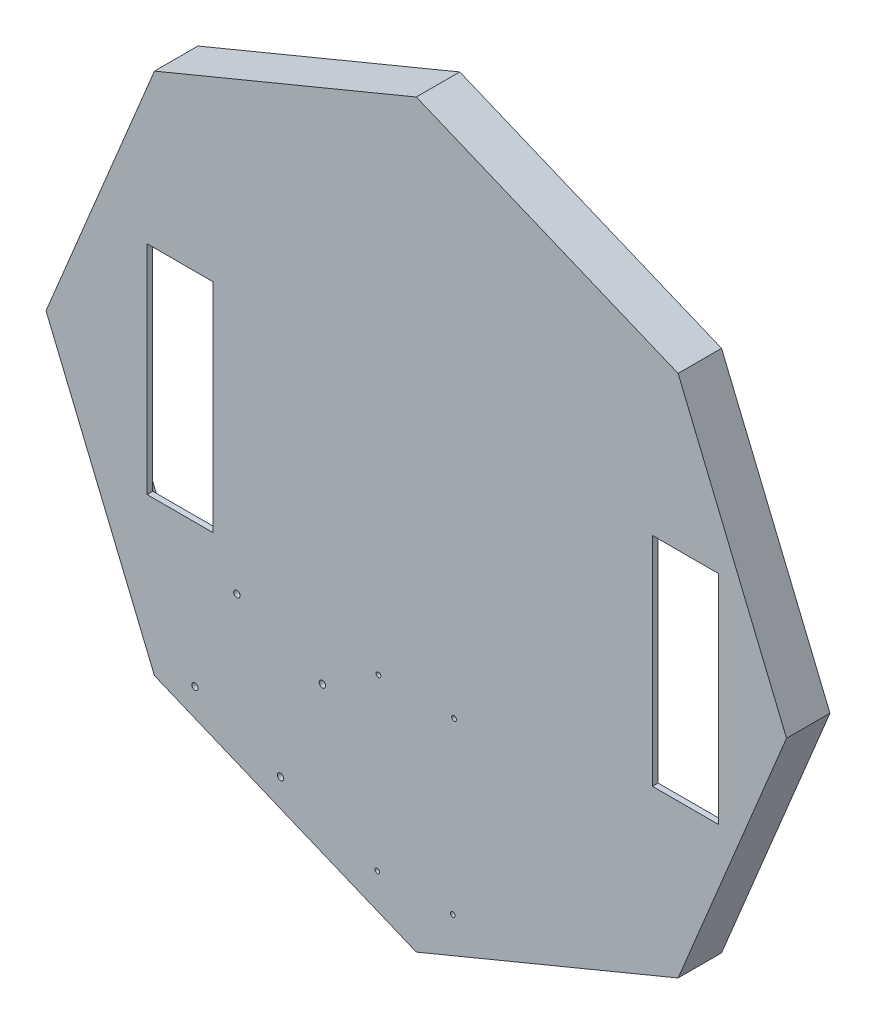
from build123d import *

# Parameters (mm, degrees)
BOSS_EXTRUDE1_DEPTH     = 3
SKETCH5_W               = 150
SKETCH5_H               = 20
BOSS_EXTRUDE2_DEPTH     = 3
MIRROR2_COPY_1_SKETCH_W = 150
MIRROR2_COPY_1_SKETCH_H = 20
MIRROR2_COPY_1_DEPTH    = 3
SKETCH6_W               = 23
SKETCH6_H               = 150
BOSS_EXTRUDE3_DEPTH     = 3
MIRROR4_COPY_1_SKETCH_W = 23
MIRROR4_COPY_1_SKETCH_H = 150
MIRROR4_COPY_1_DEPTH    = 3
MIRROR4_COPY_2_SKETCH_W = 23
MIRROR4_COPY_2_SKETCH_H = 150
MIRROR4_COPY_2_DEPTH    = 3
FILLET1_R               = 2
SKETCH4_W               = 35
SKETCH4_H               = 115
CUT_EXTRUDE1_DEPTH      = 10
TAP_DRILL_FOR_M3_TAP2_D = 2.5
TAP_DRILL_FOR_M3_TAP3_D = 2.5
M3_CLEARANCE_HOLE1_D    = 3.4


with BuildPart() as part:
    # Sketch1 → Boss-Extrude1 (new body)
    with BuildSketch(Plane.XY):
        Polygon((0, 195.984444731), (-138.581929877, 138.581929877), (-195.984444731, 0), (-138.581929877, -138.581929877), (0, -195.984444731), (138.581929877, -138.581929877), (195.984444731, 0), (138.581929877, 138.581929877), align=None)
    boss_extrude1 = extrude(amount=BOSS_EXTRUDE1_DEPTH)

    # Sketch5 → Boss-Extrude2 (add)
    with BuildSketch(Plane(origin=(-69.290964938, -167.283187304, 0), x_dir=(0.923879533, -0.382683432, 0), z_dir=(-0.382683432, -0.923879533, 0))):
        with Locations((0, -10)):
            Rectangle(SKETCH5_W, SKETCH5_H)
    boss_extrude2 = extrude(amount=-BOSS_EXTRUDE2_DEPTH)

    # Mirror1: Boss-Extrude2 across plane
    add(boss_extrude2.mirror(Plane.ZX))

    # Mirror2: Boss-Extrude2 across plane
    add(boss_extrude2.mirror(Plane(origin=(0, 0, 0), x_dir=(0, 0, 1), z_dir=(1, 0, 0))))

    # Mirror2 copy 1 sketch → Mirror2 copy 1 (add)
    with BuildSketch(Plane(origin=(69.290964938, 167.283187304, 0), x_dir=(-0.923879533, 0.382683432, 0), z_dir=(0.382683432, 0.923879533, 0))):
        with Locations((0, -10)):
            Rectangle(MIRROR2_COPY_1_SKETCH_W, MIRROR2_COPY_1_SKETCH_H)
    extrude(amount=-MIRROR2_COPY_1_DEPTH)

    # Sketch6 → Boss-Extrude3 (add)
    with BuildSketch(Plane(origin=(-167.283187304, -69.290964938, 0), x_dir=(0, 0, 1), z_dir=(-0.923879533, -0.382683432, 0))):
        with Locations((-8.5, 0)):
            Rectangle(SKETCH6_W, SKETCH6_H)
    boss_extrude3 = extrude(amount=-BOSS_EXTRUDE3_DEPTH)

    # Mirror3: Boss-Extrude3 across plane
    add(boss_extrude3.mirror(Plane.ZX))

    # Mirror4: Boss-Extrude1 across plane
    add(boss_extrude1.mirror(Plane(origin=(0, 0, 0), x_dir=(0, 0, 1), z_dir=(1, 0, 0))))

    # Mirror4 copy 1 sketch → Mirror4 copy 1 (add)
    with BuildSketch(Plane(origin=(167.283187304, 69.290964938, 0), x_dir=(0, 0, 1), z_dir=(0.923879533, 0.382683432, 0))):
        with Locations((-8.5, 0)):
            Rectangle(MIRROR4_COPY_1_SKETCH_W, MIRROR4_COPY_1_SKETCH_H)
    extrude(amount=-MIRROR4_COPY_1_DEPTH)

    # Mirror4 copy 2 sketch → Mirror4 copy 2 (add)
    with BuildSketch(Plane(origin=(167.283187304, -69.290964938, 0), x_dir=(0, 0, 1), z_dir=(0.923879533, -0.382683432, 0))):
        with Locations((-8.5, 0)):
            Rectangle(MIRROR4_COPY_2_SKETCH_W, MIRROR4_COPY_2_SKETCH_H)
    extrude(amount=-MIRROR4_COPY_2_DEPTH)

    # Fillet1
    fillet1_edges = [part.edges().sort_by_distance(p)[0] for p in [
        (-164.511548707, -68.142914641, 0),
        (-164.511548707, 68.142914641, 0),
        (164.511548707, 68.142914641, 0),
        (164.511548707, -68.142914641, 0),
        (-68.142914641, 164.511548707, 0),
        (68.142914641, 164.511548707, 0),
        (-68.142914641, -164.511548707, 0),
        (68.142914641, -164.511548707, 0),
    ]]
    fillet(fillet1_edges, radius=FILLET1_R)

    # Sketch4 → Cut-Extrude1 (cut)
    with BuildSketch(Plane(origin=(0, 0, 0), x_dir=(-1, 0, 0), z_dir=(0, 0, -1))):
        with Locations((-142.5, 0)):
            Rectangle(SKETCH4_W, SKETCH4_H)
        with Locations((125, 0)):
            Rectangle(SKETCH4_W, SKETCH4_H)
    extrude(amount=-CUT_EXTRUDE1_DEPTH, mode=Mode.SUBTRACT)

    # Tap Drill for M3 Tap2 (through all)
    with Locations(Plane(origin=(0, 0, 0), x_dir=(-1, 0, 0), z_dir=(0, 0, -1))):
        with Locations((-19.343368816, -169.062877249), (20.628515922, -169.078590597)):
            Hole(TAP_DRILL_FOR_M3_TAP2_D / 2)

    # Tap Drill for M3 Tap3 (through all)
    with Locations(Plane(origin=(0, 0, 0), x_dir=(-1, 0, 0), z_dir=(0, 0, -1))):
        with Locations((-20, -78.890298866), (20, -78.890298866)):
            Hole(TAP_DRILL_FOR_M3_TAP3_D / 2)

    # M3 Clearance Hole1 (through all)
    with Locations(Plane.XY.offset(3)):
        with Locations((-49.680592478, -98.01502722), (-71.876231555, -151.600040105), (-94.950689571, -79.263539034), (-117.146328648, -132.848551919)):
            Hole(M3_CLEARANCE_HOLE1_D / 2)


solid = part.part
